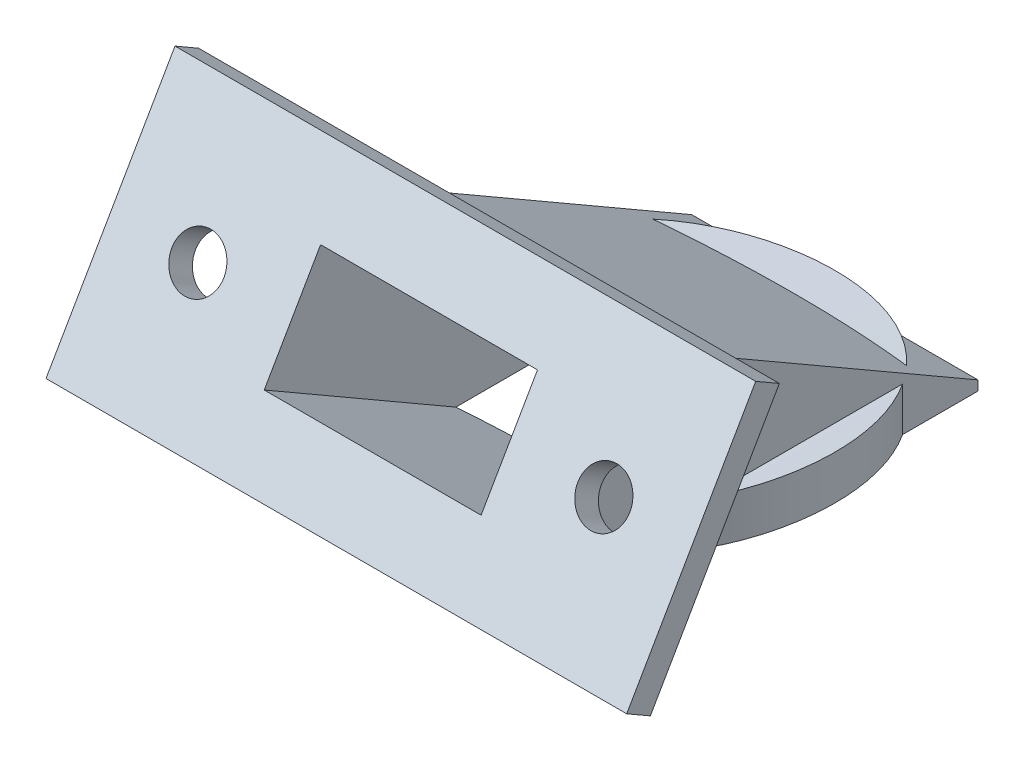
from build123d import *

# Parameters (mm, degrees)
SKETCH2_R                = 12.7
BOSS_EXTRUDE1_DEPTH      = 80.01
SKETCH3_R                = 101.6
SKETCH3_R_2              = 72.8472
SKETCH3_R_3              = 69.6722
CUT_EXTRUDE1_DEPTH       = 13.7
CUT_EXTRUDE1_DEPTH_BACK  = 13.7
SKETCH6_W                = 15.875
SKETCH6_H                = 8.255
CUT_EXTRUDE2_DEPTH       = 80.01
SKETCH5_W                = 42.5064
SKETCH5_H                = 18.8844
SKETCH5_R                = 1.905
SKETCH5_W_2              = 15.875
SKETCH5_H_2              = 8.255
BOSS_EXTRUDE2_DEPTH      = 2
SKETCH7_W                = 20.955
SKETCH7_H                = 13.335
SKETCH7_W_2              = 15.875
SKETCH7_H_2              = 8.255
BOSS_EXTRUDE3_DEPTH      = 35.528
SKETCH8_R                = 72.8472
BOSS_EXTRUDE4_DEPTH      = 34.29
BOSS_EXTRUDE4_DEPTH_BACK = 12.7


with BuildPart() as part:
    # Sketch2 → Boss-Extrude1 (new body)
    with BuildSketch(Plane.XZ):
        Circle(SKETCH2_R)
    extrude(amount=BOSS_EXTRUDE1_DEPTH)

    # Sketch3 → Cut-Extrude1 (cut, two sides)
    with BuildSketch(Plane.XY) as cut_extrude1_sk:
        Circle(SKETCH3_R)
        Circle(SKETCH3_R_2, mode=Mode.SUBTRACT)
        Circle(SKETCH3_R_3)
    extrude(amount=CUT_EXTRUDE1_DEPTH, mode=Mode.SUBTRACT)
    extrude(cut_extrude1_sk.sketch, amount=-CUT_EXTRUDE1_DEPTH_BACK, mode=Mode.SUBTRACT)

    # Sketch6 → Cut-Extrude2 (cut)
    with BuildSketch(Plane(origin=(0, -7.927243212, -13.730388006), x_dir=(1, 0, 0), z_dir=(0, 0.5, 0.866025404))):
        with Locations((0, -62.135025795)):
            Rectangle(SKETCH6_W, SKETCH6_H)
    extrude(amount=-CUT_EXTRUDE2_DEPTH, mode=Mode.SUBTRACT)


with BuildPart() as body_2:
    # Sketch5 → Boss-Extrude2 (new body)
    with BuildSketch(Plane(origin=(0, -7.927243212, -13.730388006), x_dir=(1, 0, 0), z_dir=(0, 0.5, 0.866025404))):
        with Locations((0, -62.135025795)):
            Rectangle(SKETCH5_W, SKETCH5_H)
        with Locations((14.859, -62.135025795)):
            Circle(SKETCH5_R, mode=Mode.SUBTRACT)
        with Locations((-14.859, -62.135025795)):
            Circle(SKETCH5_R, mode=Mode.SUBTRACT)
        with Locations((0, -62.135025795)):
            Rectangle(SKETCH5_W_2, SKETCH5_H_2, mode=Mode.SUBTRACT)
    extrude(amount=BOSS_EXTRUDE2_DEPTH)


with BuildPart() as body_3:
    # Sketch7 → Boss-Extrude3 (new body)
    with BuildSketch(Plane(origin=(0, -7.927243212, -13.730388006), x_dir=(-1, 0, 0), z_dir=(0, -0.5, -0.866025404))):
        with Locations((0, -62.135025795)):
            Rectangle(SKETCH7_W, SKETCH7_H)
        with Locations((0, -62.135025795)):
            Rectangle(SKETCH7_W_2, SKETCH7_H_2, mode=Mode.SUBTRACT)
    extrude(amount=BOSS_EXTRUDE3_DEPTH)


with BuildPart() as body_4:
    # Sketch8 → Boss-Extrude4 (new body, two sides)
    with BuildSketch(Plane.XY) as boss_extrude4_sk:
        Circle(SKETCH8_R)
    extrude(amount=BOSS_EXTRUDE4_DEPTH)
    extrude(boss_extrude4_sk.sketch, amount=-BOSS_EXTRUDE4_DEPTH_BACK)

    # Combine1: intersect body 3
    add(body_3.part, mode=Mode.INTERSECT)


with BuildPart() as body_2_1:
    add(body_2.part)

    # Combine2: union body 4, part
    add(body_4.part)
    add(part.part)


solid = body_2_1.part
